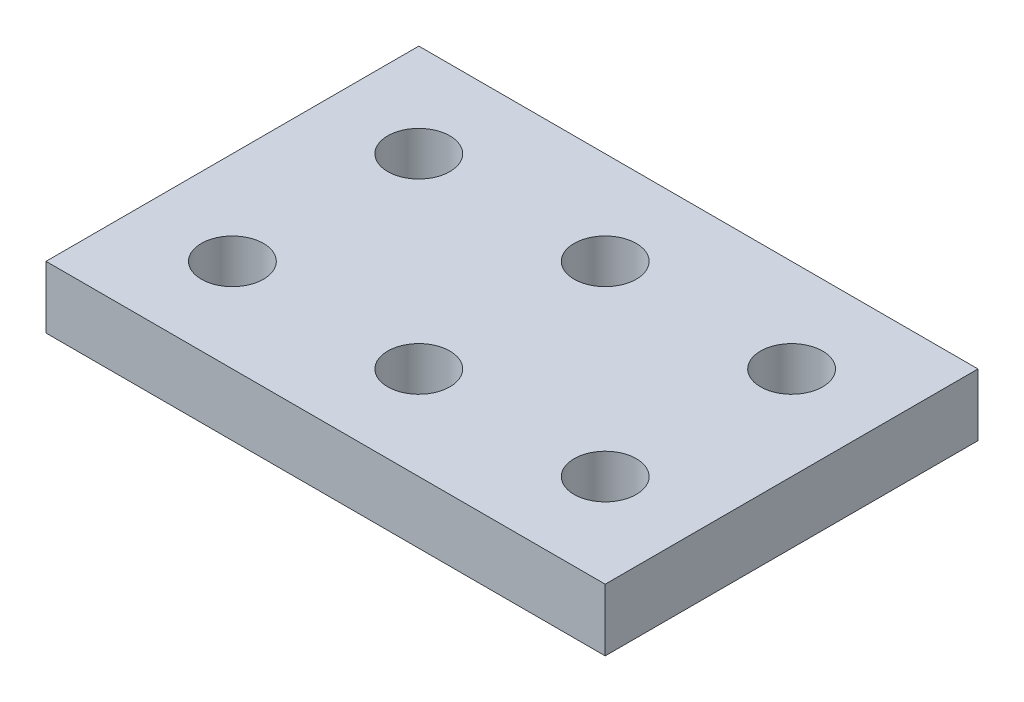
from build123d import *

# Parameters (mm, degrees)
SKETCH1_W            = 90
SKETCH1_H            = 60
BOSS_EXTRUDE1_DEPTH  = 10
SKETCH2_R            = 5
CUT_EXTRUDE1_DEPTH   = 11
LPATTERN1_COUNT      = 4
LPATTERN1_PITCH      = 30
LPATTERN1_COUNT_DIR2 = 4
LPATTERN1_PITCH_DIR2 = 30


with BuildPart() as part:
    # Sketch1 → Boss-Extrude1 (new body)
    with BuildSketch(Plane(origin=(0, 0, 0), x_dir=(1, 0, 0), z_dir=(0, 1, 0))):
        with Locations((45, 30)):
            Rectangle(SKETCH1_W, SKETCH1_H)
    extrude(amount=BOSS_EXTRUDE1_DEPTH)

    # Sketch2 → Cut-Extrude1 (cut, through all)
    with BuildSketch(Plane(origin=(0, 10, 0), x_dir=(1, 0, 0), z_dir=(0, 1, 0))):
        with Locations((15, 15)):
            Circle(SKETCH2_R)
    cut_extrude1 = extrude(amount=-CUT_EXTRUDE1_DEPTH, mode=Mode.SUBTRACT)

    # LPattern1: Cut-Extrude1 4 × 4
    with Locations(*[(i * LPATTERN1_PITCH, 0, -j * LPATTERN1_PITCH_DIR2) for i in range(LPATTERN1_COUNT) for j in range(LPATTERN1_COUNT_DIR2) if (i, j) != (0, 0)]):
        add(cut_extrude1, mode=Mode.SUBTRACT)


solid = part.part
